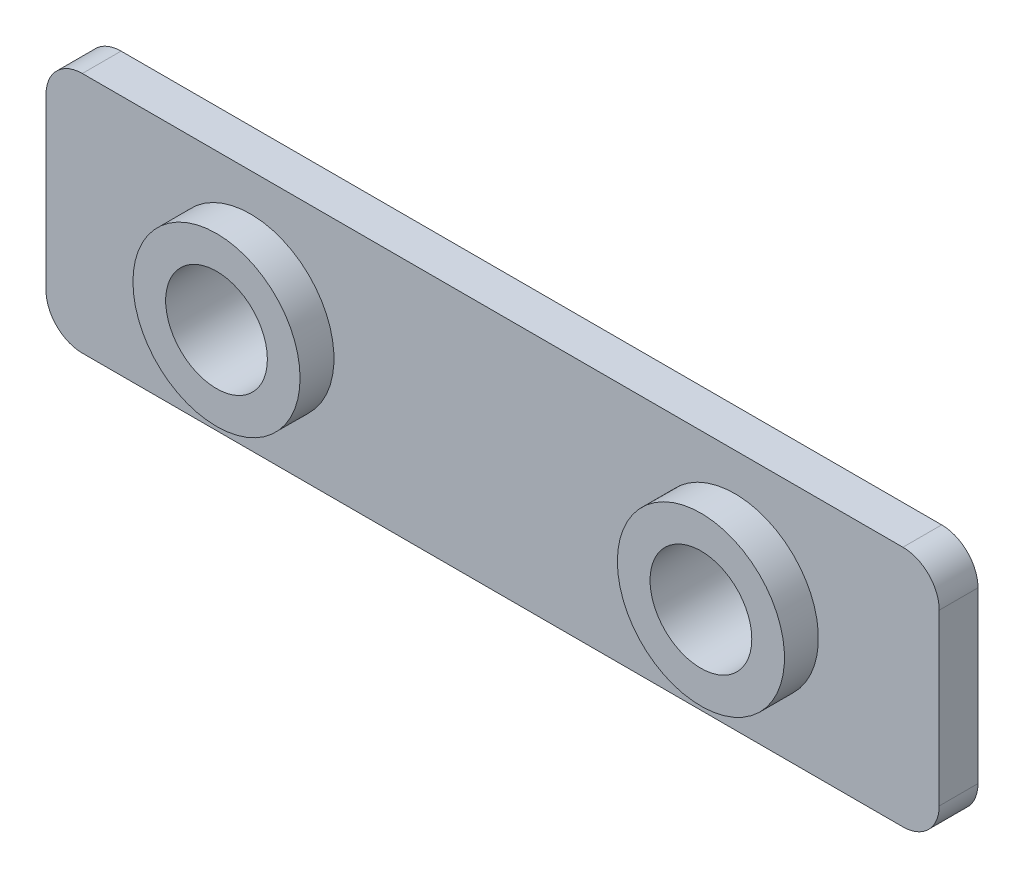
from build123d import *

# Parameters (mm, degrees)
BOSS_EXTRUDE1_DEPTH   = 1.6
SKETCH2_R             = 3.45
BOSS_EXTRUDE2_DEPTH   = 1.4
M5X0_8_TAPPED_HOLE1_D = 4.2


with BuildPart() as part:
    # Sketch1 → Boss-Extrude1 (new body)
    with BuildSketch(Plane.XY):
        with BuildLine():
            Line((1.5, 0), (35.38, 0))
            ThreePointArc((35.38, 0), (36.440660172, 0.439339828), (36.88, 1.5))
            Line((36.88, 1.5), (36.88, 8.5))
            ThreePointArc((36.88, 8.5), (36.440660172, 9.560660172), (35.38, 10))
            Line((35.38, 10), (1.5, 10))
            ThreePointArc((1.5, 10), (0.439339828, 9.560660172), (0, 8.5))
            Line((0, 8.5), (0, 1.5))
            ThreePointArc((0, 1.5), (0.439339828, 0.439339828), (1.5, 0))
        make_face()
    extrude(amount=BOSS_EXTRUDE1_DEPTH)

    # Sketch2 → Boss-Extrude2 (add)
    with BuildSketch(Plane.XY.offset(1.6)):
        with Locations((8.44, 5)):
            Circle(SKETCH2_R)
        with Locations((28.44, 5)):
            Circle(SKETCH2_R)
    extrude(amount=BOSS_EXTRUDE2_DEPTH)

    # M5x0.8 Tapped Hole1 (through all)
    with Locations(Plane.XY.offset(3)):
        with Locations((8.44, 5), (28.44, 5)):
            Hole(M5X0_8_TAPPED_HOLE1_D / 2)


solid = part.part
